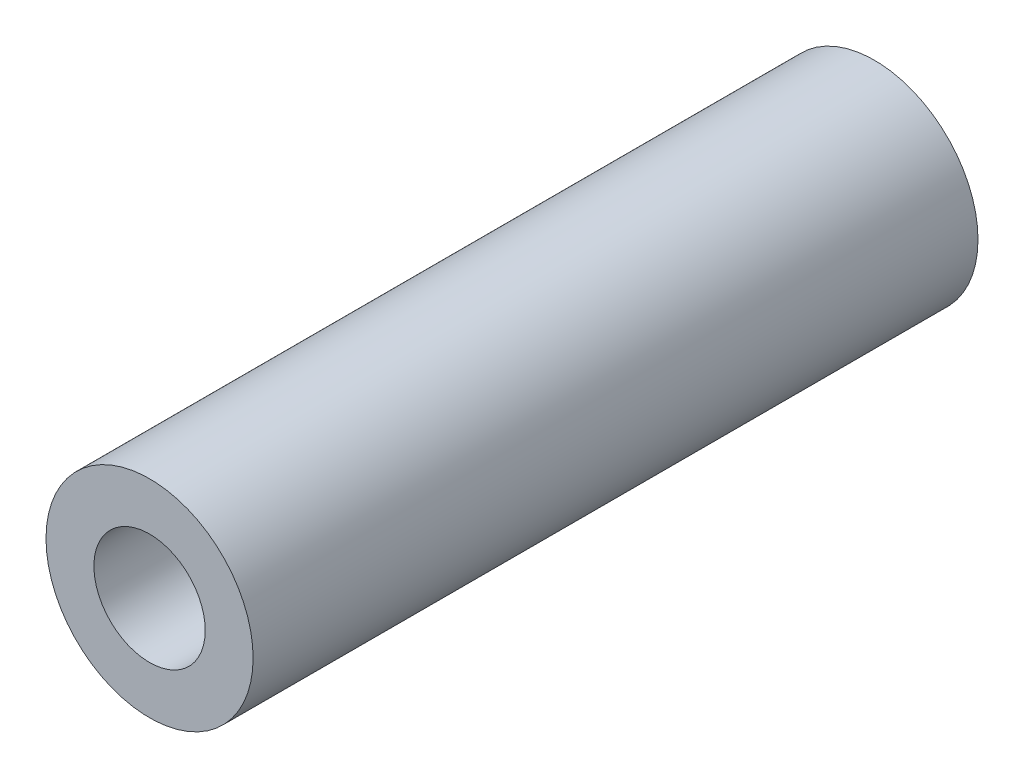
from build123d import *

# Parameters (mm, degrees)
SKETCH1_R           = 4
SKETCH1_R_2         = 2.15
BOSS_EXTRUDE1_DEPTH = 28


with BuildPart() as part:
    # Sketch1 → Boss-Extrude1 (new body)
    with BuildSketch(Plane.XY):
        Circle(SKETCH1_R)
        Circle(SKETCH1_R_2, mode=Mode.SUBTRACT)
    extrude(amount=BOSS_EXTRUDE1_DEPTH)


solid = part.part
